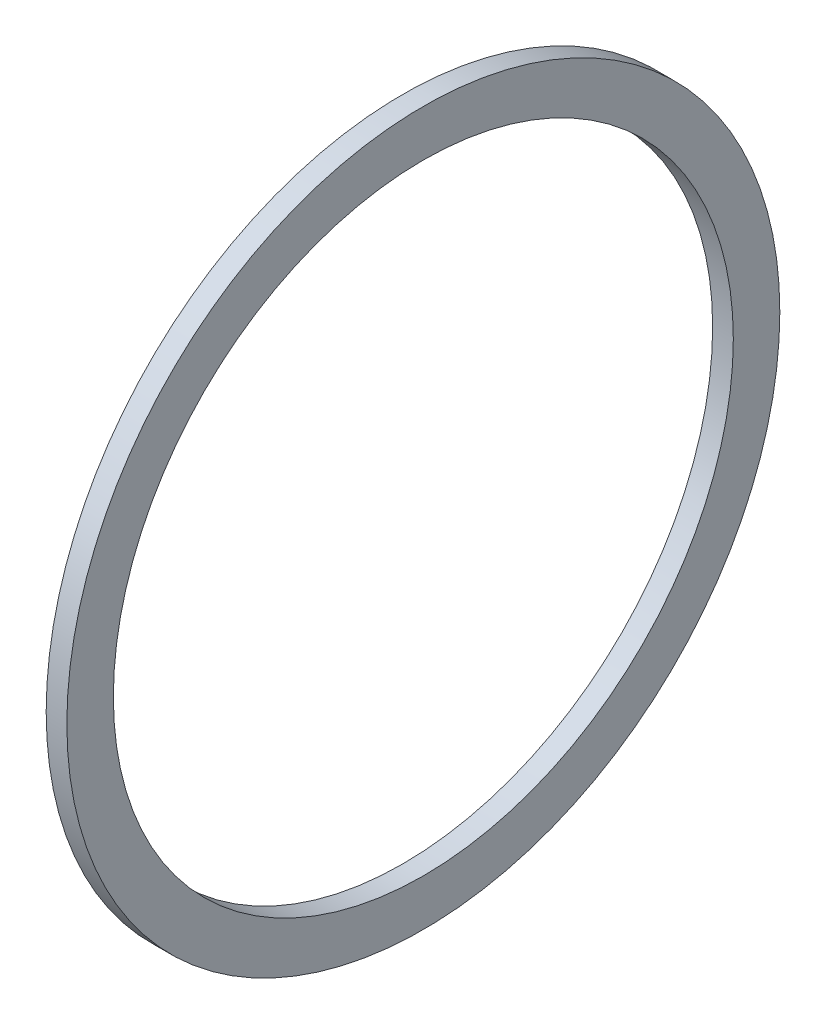
from build123d import *

# Parameters (mm, degrees)
ESQUISSE1_R        = 34.5
ESQUISSE1_R_2      = 30
BOSS_EXTRU_1_DEPTH = 2


with BuildPart() as part:
    # Esquisse1 → Boss.-Extru.1 (new body)
    with BuildSketch(Plane.YZ):
        Circle(ESQUISSE1_R)
        Circle(ESQUISSE1_R_2, mode=Mode.SUBTRACT)
    extrude(amount=BOSS_EXTRU_1_DEPTH)


solid = part.part
